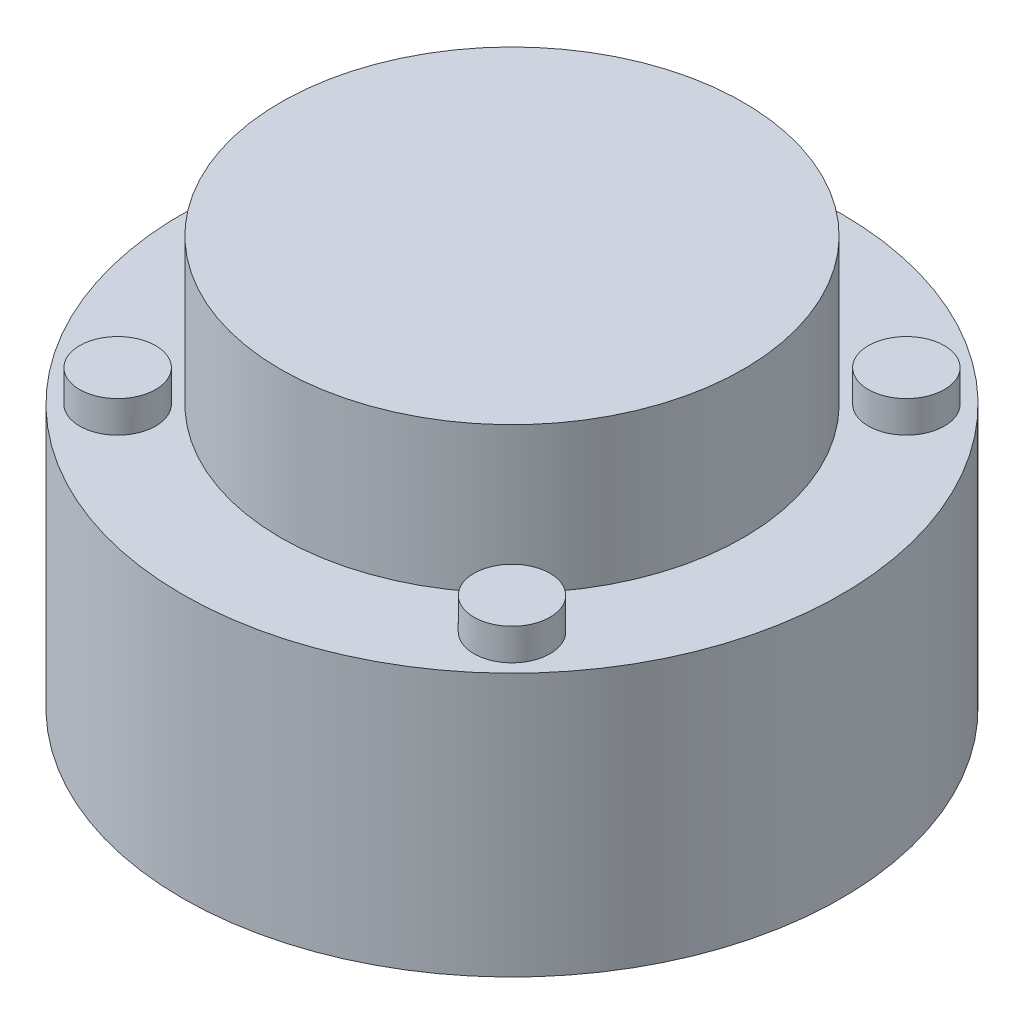
from build123d import *

# Parameters (mm, degrees)
SKETCH4_R           = 3
BOSS_EXTRUDE1_DEPTH = 2.5


with BuildPart() as part:
    # Sketch3 → Revolve1 (revolve)
    with BuildSketch(Plane.XY):
        Polygon((0, 0), (26, 0), (26, 20.758), (18.25, 20.758), (18.25, 32.258), (0, 32.258), align=None)
    revolve(axis=Axis((0, 32.258, 0), (0, -1, 0)))

    # Sketch4 → Boss-Extrude1 (add)
    with BuildSketch(Plane(origin=(0, 20.758, 0), x_dir=(1, 0, 0), z_dir=(0, 1, 0))):
        with Locations((-15.556349186, 15.556349186)):
            Circle(SKETCH4_R)
        with Locations((15.556349186, 15.556349186)):
            Circle(SKETCH4_R)
        with Locations((15.556349186, -15.556349186)):
            Circle(SKETCH4_R)
        with Locations((-15.556349186, -15.556349186)):
            Circle(SKETCH4_R)
    extrude(amount=BOSS_EXTRUDE1_DEPTH)


solid = part.part
